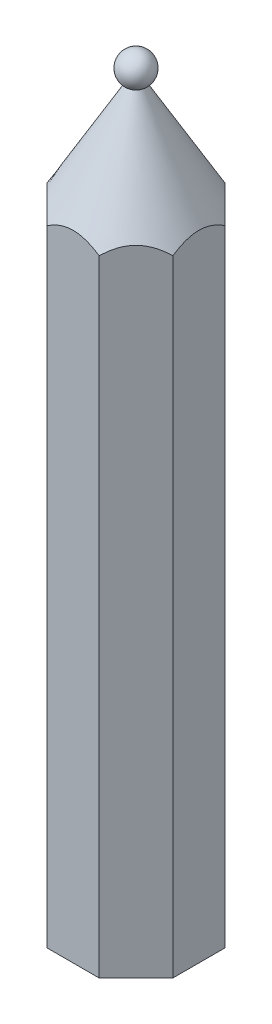
from build123d import *

# Parameters (mm, degrees)
BOSS_EXTRUDE1_DEPTH = 140


with BuildPart() as part:
    # Sketch1 → Boss-Extrude1 (new body)
    with BuildSketch(Plane(origin=(0, 0, 0), x_dir=(1, 0, 0), z_dir=(0, 1, 0))):
        Polygon((-12.071067812, -5), (-12.071067812, 5), (-5, 12.071067812), (5, 12.071067812), (12.071067812, 5), (12.071067812, -5), (5, -12.071067812), (-5, -12.071067812), align=None)
    extrude(amount=BOSS_EXTRUDE1_DEPTH)

    # Sketch3 → Cut-Revolve2 (revolve, cut)
    with BuildSketch(Plane.XY):
        Polygon((1.5, 140), (14.42266182, 117.617293159), (14.42266182, 140), align=None)
    revolve(axis=Axis((0, 140, 0), (0, -1, 0)), mode=Mode.SUBTRACT)

    # Sketch4 → Revolve1 (revolve)
    with BuildSketch(Plane.XY):
        with BuildLine():
            Line((0, 145.598076211), (0, 140))
            Line((0, 140), (1.5, 140))
            ThreePointArc((1.5, 140), (2.897777479, 143.374533347), (0, 145.598076211))
        make_face()
    revolve(axis=Axis((0, 145.598076211, 0), (0, -1, 0)))

    # Sketch5 → Cut-Revolve3 (revolve, cut)
    with BuildSketch(Plane.XY):
        Polygon((0, 0), (5, 0), (5, 110), (0, 118.660254038), align=None)
    revolve(axis=Axis((0, 118.660254038, 0), (0, -1, 0)), mode=Mode.SUBTRACT)


solid = part.part
